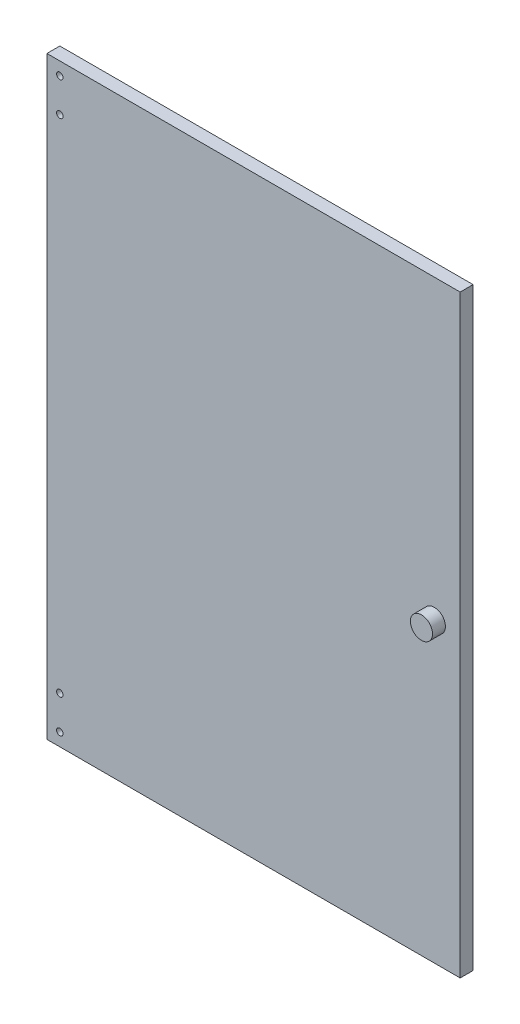
from build123d import *

# Parameters (mm, degrees)
SKETCH1_W           = 320
SKETCH1_H           = 460
SKETCH1_R           = 2.5
SKETCH1_R_2         = 3
BOSS_EXTRUDE1_DEPTH = 10
SKETCH2_R           = 8.578403593
BOSS_EXTRUDE2_DEPTH = 10


with BuildPart() as part:
    # Sketch1 → Boss-Extrude1 (new body)
    with BuildSketch(Plane.XY):
        Rectangle(SKETCH1_W, SKETCH1_H)
        with Locations((-150, -220)):
            Circle(SKETCH1_R, mode=Mode.SUBTRACT)
        with Locations((-150, 220)):
            Circle(SKETCH1_R, mode=Mode.SUBTRACT)
        with Locations((140, 0)):
            Circle(SKETCH1_R_2, mode=Mode.SUBTRACT)
        with Locations((-150, -194)):
            Circle(SKETCH1_R, mode=Mode.SUBTRACT)
        with Locations((-150, 194)):
            Circle(SKETCH1_R, mode=Mode.SUBTRACT)
    extrude(amount=BOSS_EXTRUDE1_DEPTH)

    # Sketch2 → Boss-Extrude2 (add)
    with BuildSketch(Plane.XY.offset(10)):
        with Locations((140, 0)):
            Circle(SKETCH2_R)
    extrude(amount=BOSS_EXTRUDE2_DEPTH)


solid = part.part
